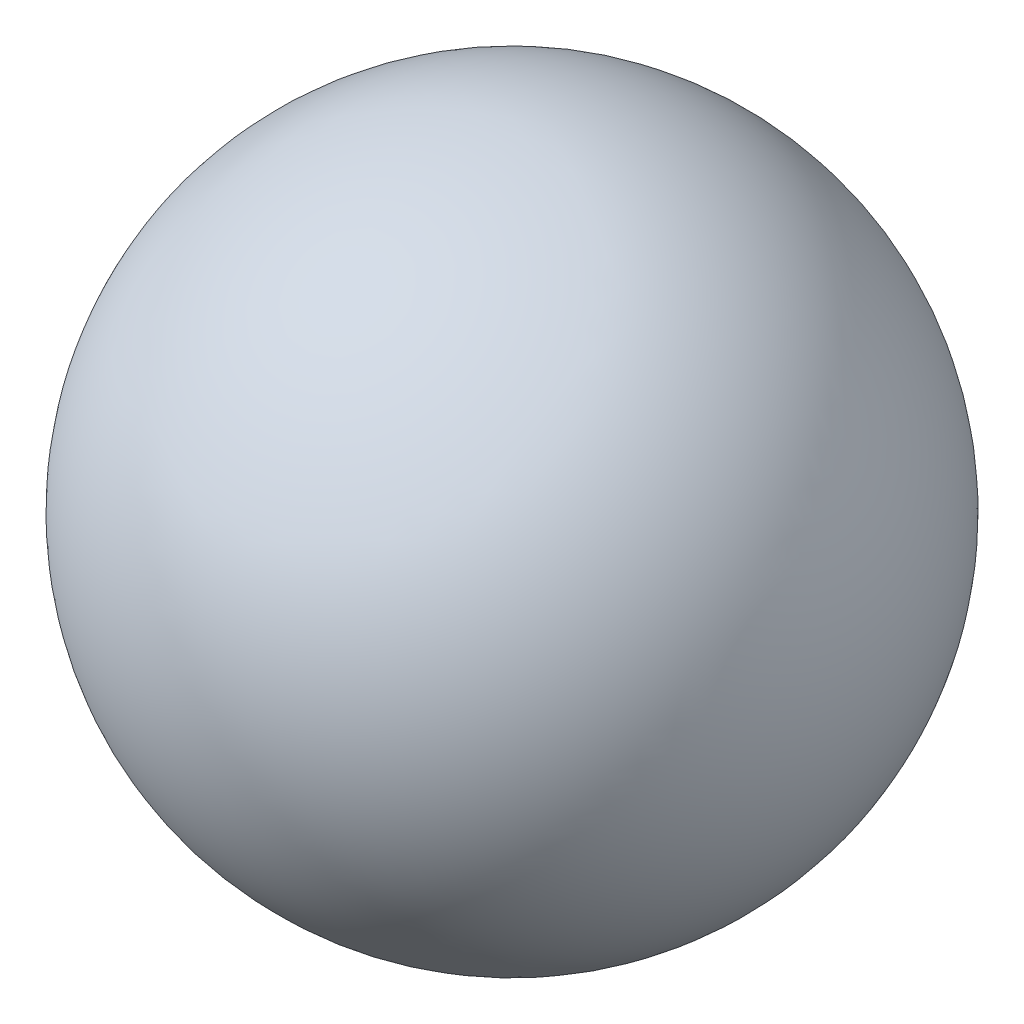
from build123d import *


with BuildPart() as part:
    # Sketch1 → Revolve1 (revolve)
    with BuildSketch(Plane(origin=(0, 0, 0), x_dir=(1, 0, 0), z_dir=(0, 1, 0))):
        with BuildLine():
            Line((-50.8, 0), (50.8, 0))
            ThreePointArc((50.8, 0), (0, -50.8), (-50.8, 0))
        make_face()
    revolve(axis=Axis((-50.8, 0, 0), (1, 0, 0)))


solid = part.part
